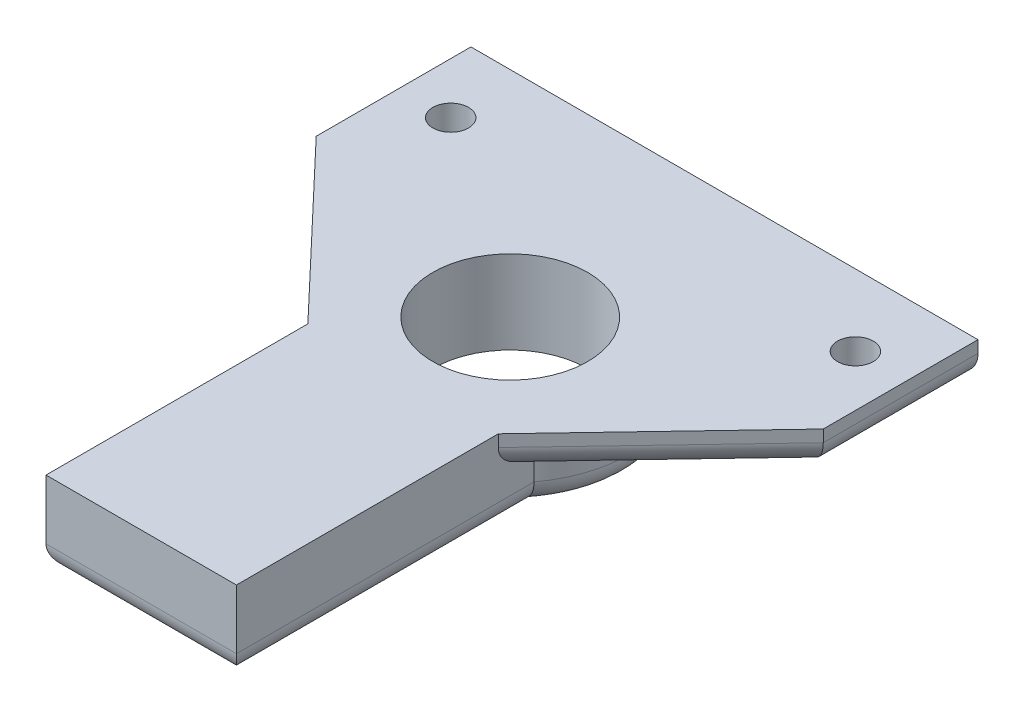
from build123d import *

# Parameters (mm, degrees)
BOSS_EXTRUDE1_DEPTH = 1.5
BOSS_EXTRUDE2_DEPTH = 2
FILLET1_R           = 1
FILLET2_R           = 1
SKETCH3_R           = 3.25
CUT_EXTRUDE1_DEPTH  = 4.5
SKETCH4_R           = 0.75
CUT_EXTRUDE2_DEPTH  = 2.5


with BuildPart() as part:
    # Sketch1 → Boss-Extrude1 (new body)
    with BuildSketch(Plane(origin=(0, 0, 0), x_dir=(1, 0, 0), z_dir=(0, 1, 0))):
        Polygon((-10.65, 18), (-4, 11), (-4, 0), (4, 0), (4, 11), (10.65, 18), (10.65, 24.5), (-10.65, 24.5), align=None)
    extrude(amount=BOSS_EXTRUDE1_DEPTH)

    # Sketch2 → Boss-Extrude2 (add)
    with BuildSketch(Plane.XZ):
        with BuildLine():
            Line((4, 0), (4, -12.5))
            ThreePointArc((4, -12.5), (0, -20.5), (-4, -12.5))
            Line((-4, -12.5), (-4, 0))
            Line((-4, 0), (4, 0))
        make_face()
    extrude(amount=BOSS_EXTRUDE2_DEPTH)

    # Fillet1
    fillet1_edges = [part.edges().sort_by_distance(p)[0] for p in [
        (0, -2, 0),
        (-4, -2, -6.25),
        (0, -2, -20.5),
        (4, -2, -6.25),
    ]]
    fillet(fillet1_edges, radius=FILLET1_R)

    # Fillet2
    fillet2_edges = [part.edges().sort_by_distance(p)[0] for p in [
        (-7.325, 0, -14.5),
        (-10.65, 0, -21.25),
        (10.65, 0, -21.25),
        (7.325, 0, -14.5),
    ]]
    fillet(fillet2_edges, radius=FILLET2_R)

    # Sketch3 → Cut-Extrude1 (cut, through all)
    with BuildSketch(Plane.XZ.offset(2)):
        with Locations((0, -15.5)):
            Circle(SKETCH3_R)
    extrude(amount=-CUT_EXTRUDE1_DEPTH, mode=Mode.SUBTRACT)

    # Sketch4 → Cut-Extrude2 (cut, through all)
    with BuildSketch(Plane.XZ):
        with Locations((-8.5, -21.5)):
            Circle(SKETCH4_R)
        with Locations((8.5, -21.5)):
            Circle(SKETCH4_R)
    extrude(amount=-CUT_EXTRUDE2_DEPTH, mode=Mode.SUBTRACT)


solid = part.part
